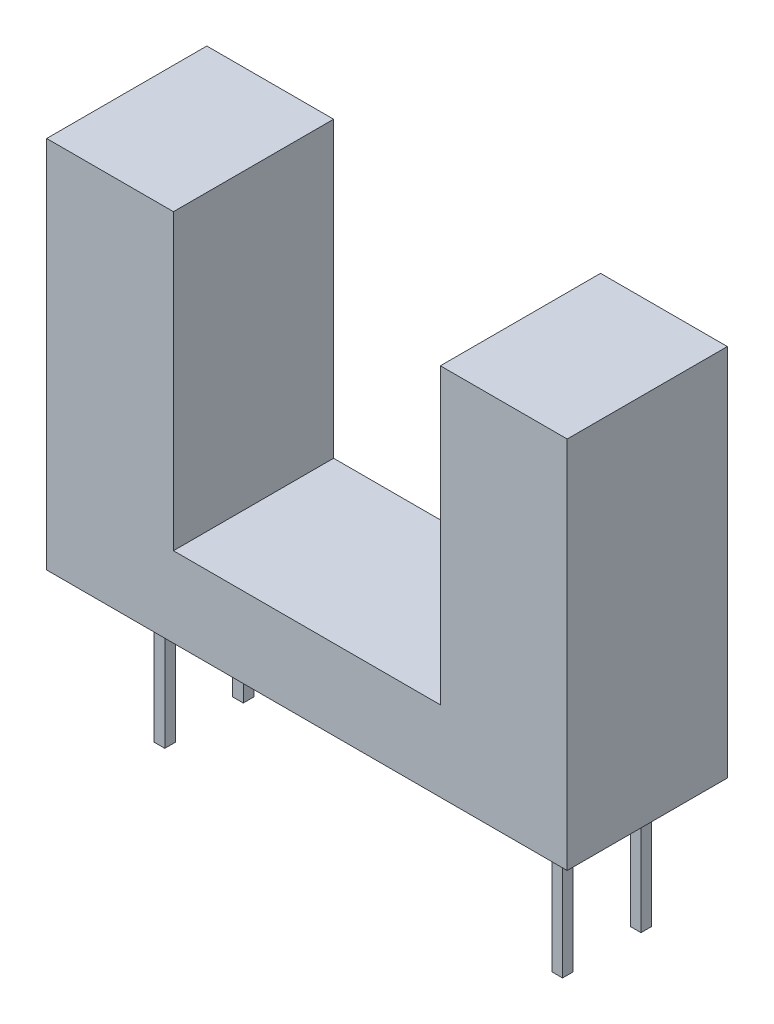
from build123d import *

# Parameters (mm, degrees)
BOSS_EXTRUDE1_DEPTH = 6
SKETCH2_W           = 0.4
SKETCH2_H           = 0.4
BOSS_EXTRUDE2_DEPTH = 5.5


with BuildPart() as part:
    # Sketch1 → Boss-Extrude1 (new body)
    with BuildSketch(Plane.XY):
        Polygon((-5, 7), (-5, -4), (5, -4), (5, 7), (9.75, 7), (9.75, -7), (-9.75, -7), (-9.75, 7), align=None)
    extrude(amount=BOSS_EXTRUDE1_DEPTH)

    # Sketch2 → Boss-Extrude2 (add)
    with BuildSketch(Plane.XZ.offset(7)):
        with Locations((-7.45, 3.874333009)):
            Rectangle(SKETCH2_W, SKETCH2_H)
        with Locations((7.45, 3.874333009)):
            Rectangle(SKETCH2_W, SKETCH2_H)
        with Locations((7.45, 0.934333009)):
            Rectangle(SKETCH2_W, SKETCH2_H)
        with Locations((-7.45, 0.934333009)):
            Rectangle(SKETCH2_W, SKETCH2_H)
    extrude(amount=BOSS_EXTRUDE2_DEPTH)


solid = part.part
